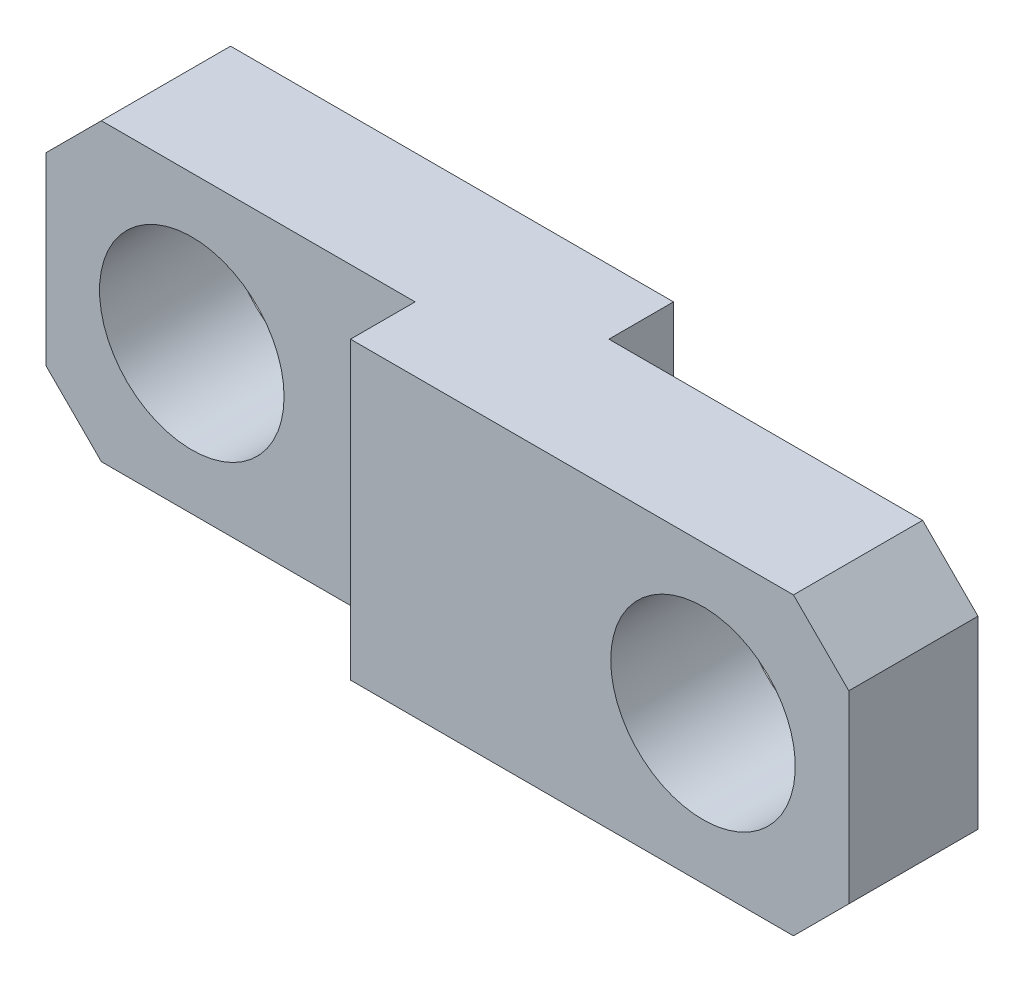
from build123d import *

# Parameters (mm, degrees)
ESQUISSE1_W             = 23.5
ESQUISSE1_H             = 8
ESQUISSE1_R             = 2.5
BASE_EXTRUSION_DEPTH    = 2.625
ESQUISSE2_W             = 10
ESQUISSE2_H             = 8
ENL_V_MAT_EXTRU_1_DEPTH = 1.75
ENL_V_MAT_EXTRU_2_DEPTH = 1.75
CHANFREIN1_SIZE         = 1.5


with BuildPart() as part:
    # Esquisse1 → Base-Extrusion (new body, symmetric)
    with BuildSketch(Plane.XY):
        with Locations((7.8, 0)):
            Rectangle(ESQUISSE1_W, ESQUISSE1_H)
        Circle(ESQUISSE1_R, mode=Mode.SUBTRACT)
        with Locations(Location((15.6, 0, 0), (0, 0, 180))):  # turned: the seam where the file's is
            Circle(ESQUISSE1_R, mode=Mode.SUBTRACT)
    extrude(amount=BASE_EXTRUSION_DEPTH, both=True)

    # Esquisse2 → Enlèv. mat.-Extru.1 (cut)
    with BuildSketch(Plane.XY.offset(2.625)):
        with Locations((1.05, 0)):
            Rectangle(ESQUISSE2_W, ESQUISSE2_H)
    extrude(amount=-ENL_V_MAT_EXTRU_1_DEPTH, mode=Mode.SUBTRACT)

    # Esquisse3 → Enlèv. mat.-Extru.2 (cut)
    with BuildSketch(Plane(origin=(0, 0, -2.625), x_dir=(-1, 0, 0), z_dir=(0, 0, -1))):
        Polygon((-9.55, -2), (-9.55, 4), (-19.55, 4), (-19.55, -4), (-6.085898385, -4), align=None)
    extrude(amount=-ENL_V_MAT_EXTRU_2_DEPTH, mode=Mode.SUBTRACT)

    # Chanfrein1
    chanfrein1_edges = [part.edges().sort_by_distance(p)[0] for p in [
        (-3.95, 4, -0.875),
        (19.55, 4, 0.875),
        (-3.95, -4, -0.875),
        (19.55, -4, 0.875),
    ]]
    chamfer(chanfrein1_edges, length=CHANFREIN1_SIZE)


solid = part.part
